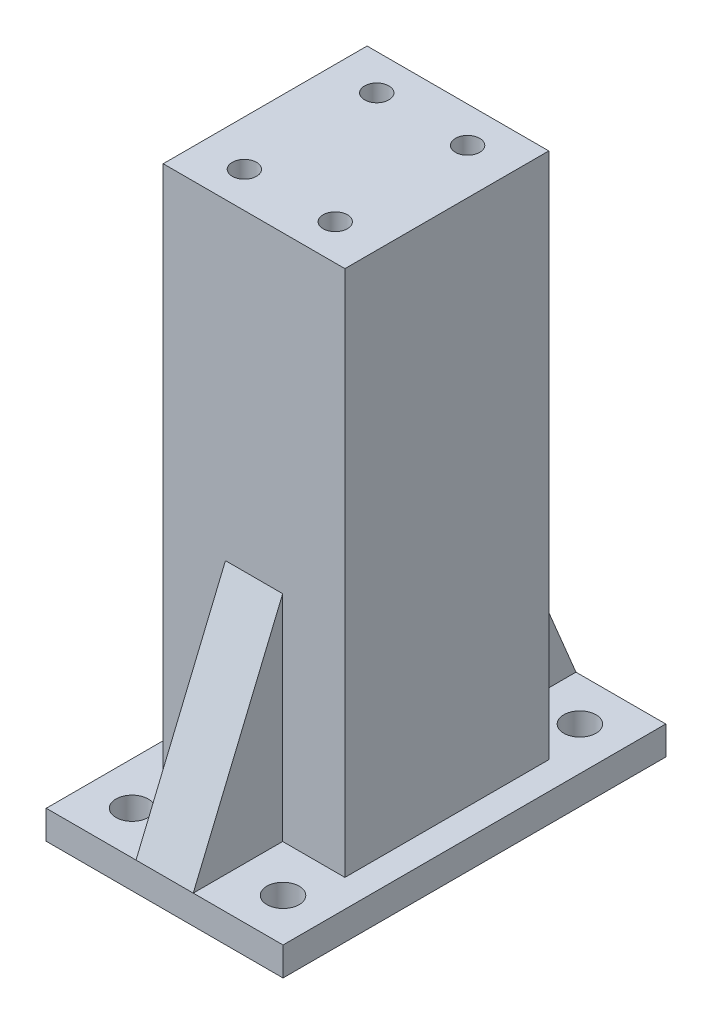
from build123d import *

# Parameters (mm, degrees)
SKETCH10_W          = 33.1
SKETCH10_H          = 53.5
BOSS_EXTRUDE7_DEPTH = 4
SKETCH12_R          = 2.25
CUT_EXTRUDE2_DEPTH  = 32.709068104
SKETCH11_W          = 25.4
SKETCH11_H          = 28.5
BOSS_EXTRUDE8_DEPTH = 73.7
RIB3_REACH          = 82.132
SKETCH13_WALL_W     = 194.764219338
SKETCH13_WALL_H     = 8
SKETCH14_R          = 1.7
CUT_EXTRUDE3_DEPTH  = 12
CUT_EXTRUDE5_START  = -5
SKETCH14_3_R        = 1.7
CUT_EXTRUDE5_DEPTH  = 2.5


with BuildPart() as part:
    # Sketch10 → Boss-Extrude7 (new body)
    with BuildSketch(Plane(origin=(0, 0, 0), x_dir=(1, 0, 0), z_dir=(0, 1, 0))):
        Rectangle(SKETCH10_W, SKETCH10_H)
    extrude(amount=-BOSS_EXTRUDE7_DEPTH)

    # Sketch12 → Cut-Extrude2 (cut, through all)
    with BuildSketch(Plane(origin=(0, 0, 0), x_dir=(1, 0, 0), z_dir=(0, 1, 0))):
        with Locations(Location((-10.55, 20.75, 0), (0, 0, 270))):
            Circle(SKETCH12_R)
        with Locations(Location((10.55, 20.75, 0), (0, 0, 270))):
            Circle(SKETCH12_R)
        with Locations(Location((10.55, -20.75, 0), (0, 0, 270))):
            Circle(SKETCH12_R)
        with Locations(Location((-10.55, -20.75, 0), (0, 0, 270))):
            Circle(SKETCH12_R)
    extrude(amount=-CUT_EXTRUDE2_DEPTH, mode=Mode.SUBTRACT)

    # Sketch11 → Boss-Extrude8 (add)
    with BuildSketch(Plane(origin=(0, 0, 0), x_dir=(1, 0, 0), z_dir=(0, 1, 0))):
        Rectangle(SKETCH11_W, SKETCH11_H)
    extrude(amount=BOSS_EXTRUDE8_DEPTH)

    # Sketch13 wall → Rib3 (add, up to next)
    with BuildSketch(Plane(origin=(0, 15, -20.5), x_dir=(0, 0.923076923077, 0.384615384615), z_dir=(0, -0.384615384615, 0.923076923077)), mode=Mode.PRIVATE) as rib3_sk1:
        Rectangle(SKETCH13_WALL_W, SKETCH13_WALL_H)
    rib3_tool1 = extrude(rib3_sk1.sketch, amount=RIB3_REACH, mode=Mode.PRIVATE) - part.part
    rib3 = rib3_tool1.solids().sort_by_distance((0, 15, -20.5))[0]
    add(rib3)

    # Mirror1: Rib3 across plane
    add(rib3.mirror(Plane.XY))

    # Sketch14 → Cut-Extrude3 (cut)
    with BuildSketch(Plane(origin=(0, 73.7, 0), x_dir=(1, 0, 0), z_dir=(0, 1, 0))):
        with Locations(Location((-6.35, 9.25, 0), (0, 0, 270))):
            Circle(SKETCH14_R)
        with Locations(Location((6.35, 9.25, 0), (0, 0, 270))):
            Circle(SKETCH14_R)
        with Locations(Location((-6.35, -9.25, 0), (0, 0, 270))):
            Circle(SKETCH14_R)
        with Locations(Location((6.35, -9.25, 0), (0, 0, 270))):
            Circle(SKETCH14_R)
    extrude(amount=-CUT_EXTRUDE3_DEPTH, mode=Mode.SUBTRACT)

    # Sketch14_3 → Cut-Extrude5 (cut)
    with BuildSketch(Plane(origin=(0, 73.7, 0), x_dir=(1, 0, 0), z_dir=(0, 1, 0)).offset(CUT_EXTRUDE5_START)):
        Polygon((-2.943633412, 9.25), (-4.646816706, 12.2), (-8.053183294, 12.2), (-9.756366588, 9.25), (-8.053183294, 6.3), (-4.646816706, 6.3), align=None)
        with Locations(Location((-6.35, 9.25, 0), (0, 0, 270))):
            Circle(SKETCH14_3_R, mode=Mode.SUBTRACT)
        Polygon((9.756366588, 9.25), (8.053183294, 12.2), (4.646816706, 12.2), (2.943633412, 9.25), (4.646816706, 6.3), (8.053183294, 6.3), align=None)
        with Locations(Location((6.35, 9.25, 0), (0, 0, 270))):
            Circle(SKETCH14_3_R, mode=Mode.SUBTRACT)
        Polygon((9.756366588, -9.25), (8.053183294, -6.3), (4.646816706, -6.3), (2.943633412, -9.25), (4.646816706, -12.2), (8.053183294, -12.2), align=None)
        with Locations(Location((6.35, -9.25, 0), (0, 0, 270))):
            Circle(SKETCH14_3_R, mode=Mode.SUBTRACT)
        Polygon((-2.943633412, -9.25), (-4.646816706, -6.3), (-8.053183294, -6.3), (-9.756366588, -9.25), (-8.053183294, -12.2), (-4.646816706, -12.2), align=None)
        with Locations(Location((-6.35, -9.25, 0), (0, 0, 270))):
            Circle(SKETCH14_3_R, mode=Mode.SUBTRACT)
    extrude(amount=-CUT_EXTRUDE5_DEPTH, mode=Mode.SUBTRACT)


solid = part.part
